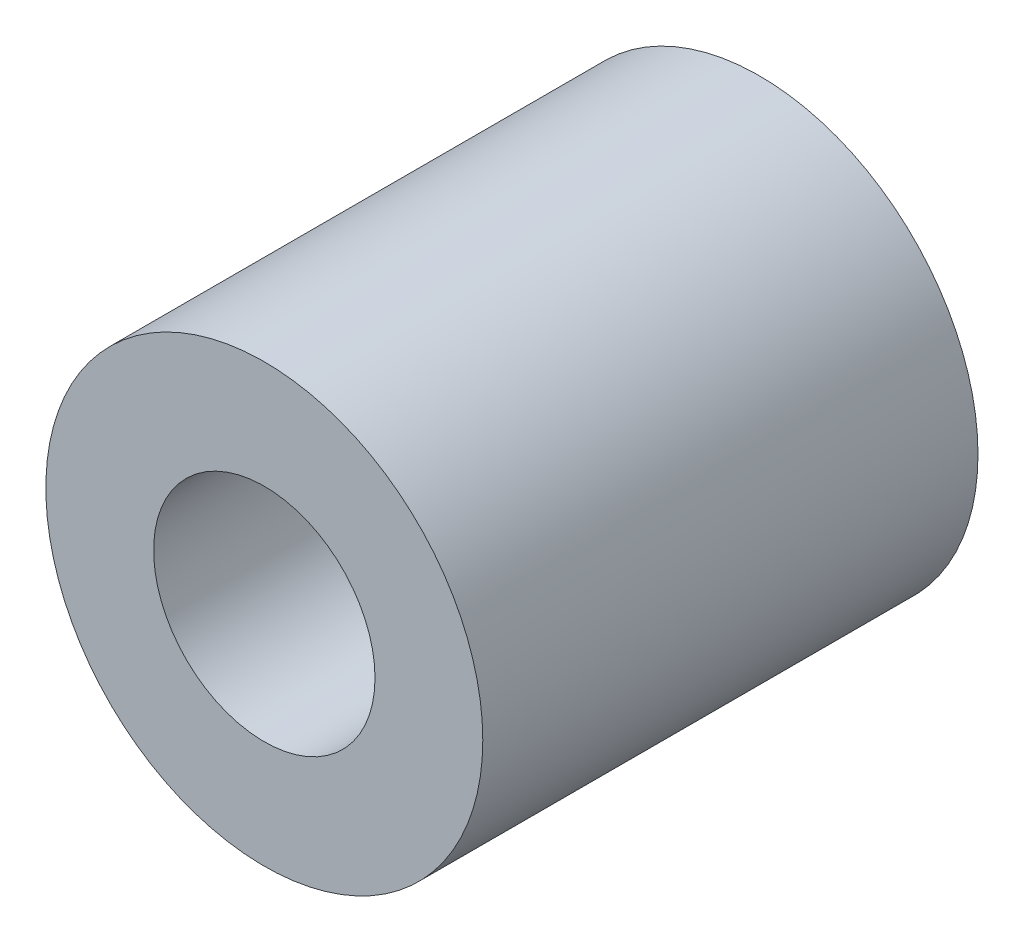
from build123d import *

# Parameters (mm, degrees)
SKETCH1_R           = 9.525
SKETCH1_R_2         = 4.826
BOSS_EXTRUDE1_DEPTH = 21.59


with BuildPart() as part:
    # Sketch1 → Boss-Extrude1 (new body)
    with BuildSketch(Plane.XY):
        Circle(SKETCH1_R)
        Circle(SKETCH1_R_2, mode=Mode.SUBTRACT)
    extrude(amount=BOSS_EXTRUDE1_DEPTH)


solid = part.part
